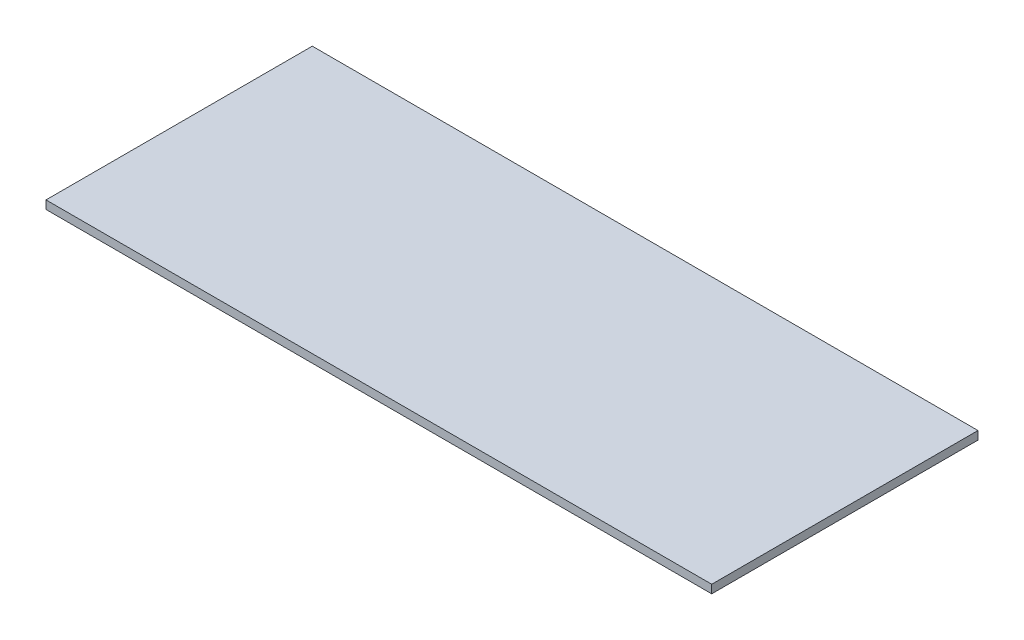
from build123d import *

# Parameters (mm, degrees)
CROQUIS1_W              = 508
CROQUIS1_H              = 203.2
SALIENTE_EXTRUIR1_DEPTH = 6.35


with BuildPart() as part:
    # Croquis1 → Saliente-Extruir1 (new body)
    with BuildSketch(Plane(origin=(0, 0, 0), x_dir=(1, 0, 0), z_dir=(0, 1, 0))):
        Rectangle(CROQUIS1_W, CROQUIS1_H)
    extrude(amount=SALIENTE_EXTRUIR1_DEPTH)


solid = part.part
